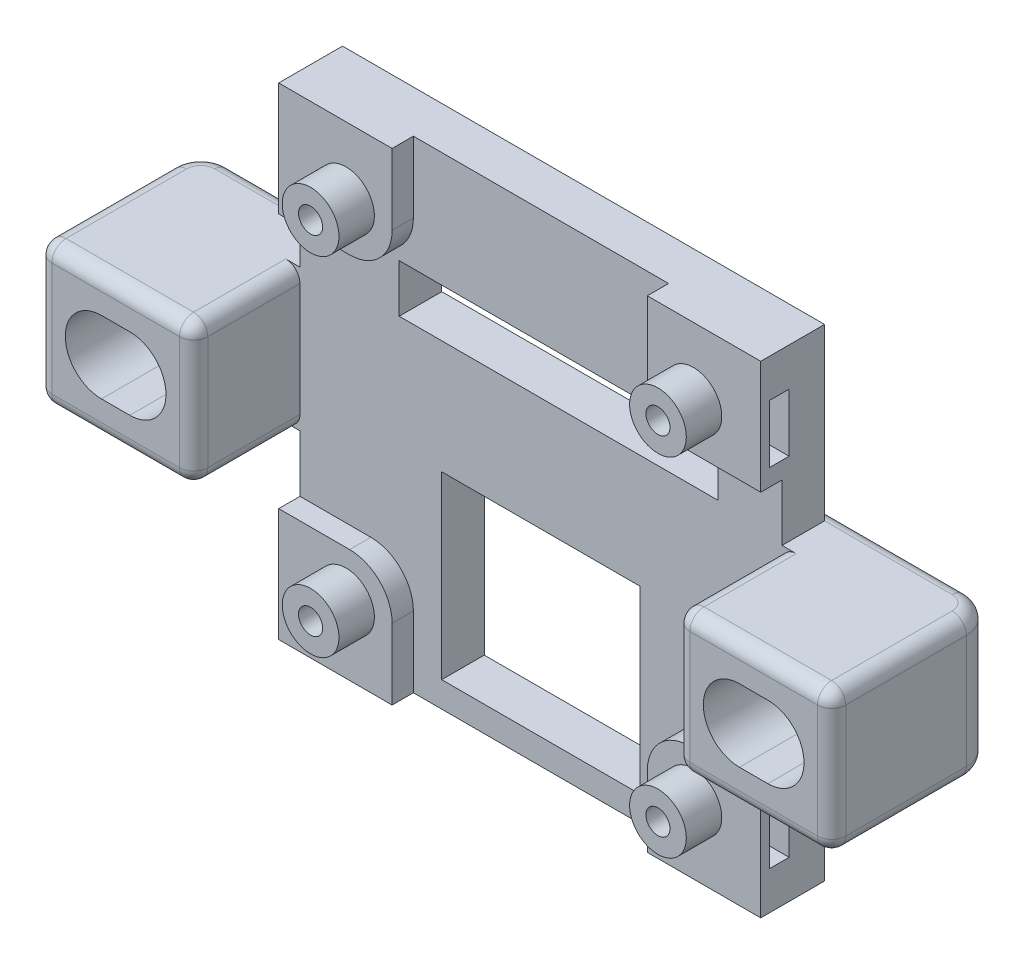
from build123d import *

# Parameters (mm, degrees)
SKETCH2_W                     = 34
SKETCH2_H                     = 34
BOSS_EXTRUDE_MAIN_DEPTH       = 4.5
SKETCH9_W                     = 14
SKETCH9_H                     = 12.7
CUT_USBC_HOLE_DEPTH           = 25.459149617
SKETCH10_W                    = 22.5
SKETCH10_H                    = 3.4
CUT_FOURPIN_NOTCH_DEPTH       = 15.7
SKETCH11_R                    = 2
BOSS_EXTRUDE_PEGSPACERS_DEPTH = 2.5
F_2_0MM_HOLES_FOR_PEGS_D      = 1.7
F_2_0MM_HOLES_FOR_PEGS_DEPTH  = 4
F_2_0MM_HOLES_FOR_PEGS_TIP    = 0.510731526
SKETCH15_R                    = 15.4
SKETCH15_R_2                  = 12
CUT_SM1_DEPTH                 = 1
CUT_HEXNUTRIGHT_DEPTH         = 39.65229618
CUT_HEXNUTRIGHT_DEPTH_BACK    = 6.75
SKETCH18_W                    = 1.4
SKETCH18_H                    = 4.1
SKETCH19_W                    = 1.4
SKETCH19_H                    = 4.1
CUT_HEXNUTLEFT_DEPTH          = 6.75
SKETCH20_W                    = 18
SKETCH20_H                    = 34
CUT_EXTRUDE2_DEPTH            = 1.5
SKETCH21_W                    = 34
SKETCH21_H                    = 18
CUT_EXTRUDE3_DEPTH            = 1.5
SKETCH22_W                    = 13
SKETCH22_H                    = 10
BOSS_EXTRUDE1_DEPTH           = 10.5
CUT_EXTRUDE4_DEPTH            = 15
SKETCH25_W                    = 2
SKETCH25_H                    = 10
CUT_EXTRUDE5_DEPTH            = 15
SKETCH22_2_W                  = 13
SKETCH22_2_H                  = 10
BOSS_EXTRUDE2_DEPTH           = 1
CUT_EXTRUDE6_START            = 2
CUT_EXTRUDE6_DEPTH            = 2
FILLET5_R                     = 3
FILLET4_R                     = 3
FILLET3_R                     = 3
FILLET2_R                     = 3
FILLET7_R                     = 2
FILLET8_R                     = 2
FILLET9_R                     = 1
FILLET10_R                    = 1
FILLET11_R                    = 1
FILLET12_R                    = 1
FILLET13_R                    = 1
FILLET14_R                    = 1
FILLET15_R                    = 1
FILLET16_R                    = 1


with BuildPart() as part:
    # Sketch2 → Boss-Extrude Main (new body)
    with BuildSketch(Plane.XY):
        Rectangle(SKETCH2_W, SKETCH2_H)
    extrude(amount=BOSS_EXTRUDE_MAIN_DEPTH)

    # Sketch9 → Cut-USBc hole (cut, through all)
    with BuildSketch(Plane.XY.offset(4.5)):
        with Locations((0, -8.85)):
            Rectangle(SKETCH9_W, SKETCH9_H)
    extrude(amount=-CUT_USBC_HOLE_DEPTH, mode=Mode.SUBTRACT)

    # Sketch10 → Cut-FourPin Notch (cut)
    with BuildSketch(Plane.XY.offset(4.5)):
        with Locations((1.25, 7.2)):
            Rectangle(SKETCH10_W, SKETCH10_H)
    extrude(amount=-CUT_FOURPIN_NOTCH_DEPTH, mode=Mode.SUBTRACT)

    # Sketch11 → Boss-Extrude_PegSpacers (add)
    with BuildSketch(Plane.XY.offset(4.5)):
        with Locations((-12.25, 12.25)):
            Circle(SKETCH11_R)
        with Locations((12.25, 12.25)):
            Circle(SKETCH11_R)
        with Locations((12.25, -12.25)):
            Circle(SKETCH11_R)
        with Locations((-12.25, -12.25)):
            Circle(SKETCH11_R)
    extrude(amount=BOSS_EXTRUDE_PEGSPACERS_DEPTH)

    # Ø2.0mm Holes for Pegs
    with Locations(Plane(origin=(-12.25, 12.25, 7), x_dir=(1, 0, 0), z_dir=(0, 0, 1))):
        with Locations((0, 0), (24.5, 0), (24.5, -24.5), (0, -24.5)):
            Hole(F_2_0MM_HOLES_FOR_PEGS_D / 2, depth=F_2_0MM_HOLES_FOR_PEGS_DEPTH)
            with Locations((0, 0, -(F_2_0MM_HOLES_FOR_PEGS_DEPTH + F_2_0MM_HOLES_FOR_PEGS_TIP / 2))):  # 118° drill point
                Cone(0, F_2_0MM_HOLES_FOR_PEGS_D / 2, F_2_0MM_HOLES_FOR_PEGS_TIP, mode=Mode.SUBTRACT)

    # Sketch15 → Cut-SM1 (cut)
    with BuildSketch(Plane(origin=(0, 0, 0), x_dir=(-1, 0, 0), z_dir=(0, 0, -1))):
        with Locations((0, -11)):
            Circle(SKETCH15_R)
        with Locations((0, -11)):
            Circle(SKETCH15_R_2, mode=Mode.SUBTRACT)
    extrude(amount=-CUT_SM1_DEPTH, mode=Mode.SUBTRACT)

    # Sketch18 → Cut-HexNutRight (cut, two sides: drawn at the far end of the back side and taken through both)
    with BuildSketch(Plane(origin=(17, 0, 0), x_dir=(0, 0, -1), z_dir=(1, 0, 0)).offset(-CUT_HEXNUTRIGHT_DEPTH_BACK)):
        with Locations((-3.2, -12.25)):
            Rectangle(SKETCH18_W, SKETCH18_H)
        with Locations((-3.2, 12.25)):
            Rectangle(SKETCH18_W, SKETCH18_H)
    extrude(amount=CUT_HEXNUTRIGHT_DEPTH + CUT_HEXNUTRIGHT_DEPTH_BACK, mode=Mode.SUBTRACT)

    # Sketch19 → Cut-HexNutLeft (cut)
    with BuildSketch(Plane.ZY.offset(17)):
        with Locations((3.2, 12.25)):
            Rectangle(SKETCH19_W, SKETCH19_H)
        with Locations((3.2, -12.25)):
            Rectangle(SKETCH19_W, SKETCH19_H)
    extrude(amount=-CUT_HEXNUTLEFT_DEPTH, mode=Mode.SUBTRACT)

    # Sketch20 → Cut-Extrude2 (cut)
    with BuildSketch(Plane.XY.offset(4.5)):
        Rectangle(SKETCH20_W, SKETCH20_H)
    extrude(amount=-CUT_EXTRUDE2_DEPTH, mode=Mode.SUBTRACT)

    # Sketch21 → Cut-Extrude3 (cut)
    with BuildSketch(Plane.XY.offset(4.5)):
        Rectangle(SKETCH21_W, SKETCH21_H)
    extrude(amount=-CUT_EXTRUDE3_DEPTH, mode=Mode.SUBTRACT)

    # Sketch22 → Boss-Extrude1 (add)
    with BuildSketch(Plane.XY):
        with Locations((-21.5, 0)):
            Rectangle(SKETCH22_W, SKETCH22_H)
        with Locations((21.5, 0)):
            Rectangle(SKETCH22_W, SKETCH22_H)
    extrude(amount=BOSS_EXTRUDE1_DEPTH)

    # Sketch24 → Cut-Extrude4 (cut)
    with BuildSketch(Plane(origin=(0, 0, 0), x_dir=(-1, 0, 0), z_dir=(0, 0, -1))):
        with BuildLine():
            Line((21.5, 2.55), (23.5, 2.55))
            ThreePointArc((23.5, 2.55), (26.05, 0), (23.5, -2.55))
            Line((23.5, -2.55), (21.5, -2.55))
            ThreePointArc((21.5, -2.55), (18.95, 0), (21.5, 2.55))
        make_face()
        with BuildLine():
            Line((-21.5, -2.55), (-23.5, -2.55))
            ThreePointArc((-23.5, -2.55), (-26.05, 0), (-23.5, 2.55))
            Line((-23.5, 2.55), (-21.5, 2.55))
            ThreePointArc((-21.5, 2.55), (-18.95, 0), (-21.5, -2.55))
        make_face()
    extrude(amount=-CUT_EXTRUDE4_DEPTH, mode=Mode.SUBTRACT)

    # Sketch25 → Cut-Extrude5 (cut)
    with BuildSketch(Plane.XY.offset(3)):
        with Locations((-16, 0)):
            Rectangle(SKETCH25_W, SKETCH25_H)
        with Locations((16, 0)):
            Rectangle(SKETCH25_W, SKETCH25_H)
    extrude(amount=CUT_EXTRUDE5_DEPTH, mode=Mode.SUBTRACT)

    # Sketch22_2 → Boss-Extrude2 (add)
    with BuildSketch(Plane.XY):
        with Locations((-21.5, 0)):
            Rectangle(SKETCH22_2_W, SKETCH22_2_H)
        with Locations((21.5, 0)):
            Rectangle(SKETCH22_2_W, SKETCH22_2_H)
    extrude(amount=-BOSS_EXTRUDE2_DEPTH)

    # Sketch24_2 → Cut-Extrude6 (cut)
    with BuildSketch(Plane(origin=(0, 0, 0), x_dir=(-1, 0, 0), z_dir=(0, 0, -1)).offset(CUT_EXTRUDE6_START)):
        with BuildLine():
            Line((21.5, 2.55), (23.5, 2.55))
            ThreePointArc((23.5, 2.55), (26.05, 0), (23.5, -2.55))
            Line((23.5, -2.55), (21.5, -2.55))
            ThreePointArc((21.5, -2.55), (18.95, 0), (21.5, 2.55))
        make_face()
        with BuildLine():
            Line((-21.5, -2.55), (-23.5, -2.55))
            ThreePointArc((-23.5, -2.55), (-26.05, 0), (-23.5, 2.55))
            Line((-23.5, 2.55), (-21.5, 2.55))
            ThreePointArc((-21.5, 2.55), (-18.95, 0), (-21.5, -2.55))
        make_face()
    extrude(amount=-CUT_EXTRUDE6_DEPTH, mode=Mode.SUBTRACT)

    # Fillet5
    fillet5_edges = [part.edges().sort_by_distance(p)[0] for p in [
        (-9, -9, 3.75),
    ]]
    fillet(fillet5_edges, radius=FILLET5_R)

    # Fillet4
    fillet4_edges = [part.edges().sort_by_distance(p)[0] for p in [
        (9, -9, 3.75),
    ]]
    fillet(fillet4_edges, radius=FILLET4_R)

    # Fillet3
    fillet3_edges = [part.edges().sort_by_distance(p)[0] for p in [
        (-9, 9, 3.75),
    ]]
    fillet(fillet3_edges, radius=FILLET3_R)

    # Fillet2
    fillet2_edges = [part.edges().sort_by_distance(p)[0] for p in [
        (9, 9, 3.75),
    ]]
    fillet(fillet2_edges, radius=FILLET2_R)

    # Fillet7
    fillet7_edges = [part.edges().sort_by_distance(p)[0] for p in [
        (-28, 0, -1),
    ]]
    fillet(fillet7_edges, radius=FILLET7_R)

    # Fillet8
    fillet8_edges = [part.edges().sort_by_distance(p)[0] for p in [
        (28, 0, -1),
    ]]
    fillet(fillet8_edges, radius=FILLET8_R)

    # Fillet9
    fillet9_edges = [part.edges().sort_by_distance(p)[0] for p in [
        (-28, 0, 10.5),
    ]]
    fillet(fillet9_edges, radius=FILLET9_R)

    # Fillet10
    fillet10_edges = [part.edges().sort_by_distance(p)[0] for p in [
        (-22, 5, 10.5),
    ]]
    fillet(fillet10_edges, radius=FILLET10_R)

    # Fillet11
    fillet11_edges = [part.edges().sort_by_distance(p)[0] for p in [
        (-17, -0.5, 10.5),
    ]]
    fillet(fillet11_edges, radius=FILLET11_R)

    # Fillet12
    fillet12_edges = [part.edges().sort_by_distance(p)[0] for p in [
        (-22.5, -5, 10.5),
    ]]
    fillet(fillet12_edges, radius=FILLET12_R)

    # Fillet13
    fillet13_edges = [part.edges().sort_by_distance(p)[0] for p in [
        (28, -5, 5.75),
    ]]
    fillet(fillet13_edges, radius=FILLET13_R)

    # Fillet14
    fillet14_edges = [part.edges().sort_by_distance(p)[0] for p in [
        (28, 5, 5.75),
    ]]
    fillet(fillet14_edges, radius=FILLET14_R)

    # Fillet15
    fillet15_edges = [part.edges().sort_by_distance(p)[0] for p in [
        (28, 0, 10.5),
    ]]
    fillet(fillet15_edges, radius=FILLET15_R)

    # Fillet16
    fillet16_edges = [part.edges().sort_by_distance(p)[0] for p in [
        (17, 0, 10.5),
    ]]
    fillet(fillet16_edges, radius=FILLET16_R)


solid = part.part
